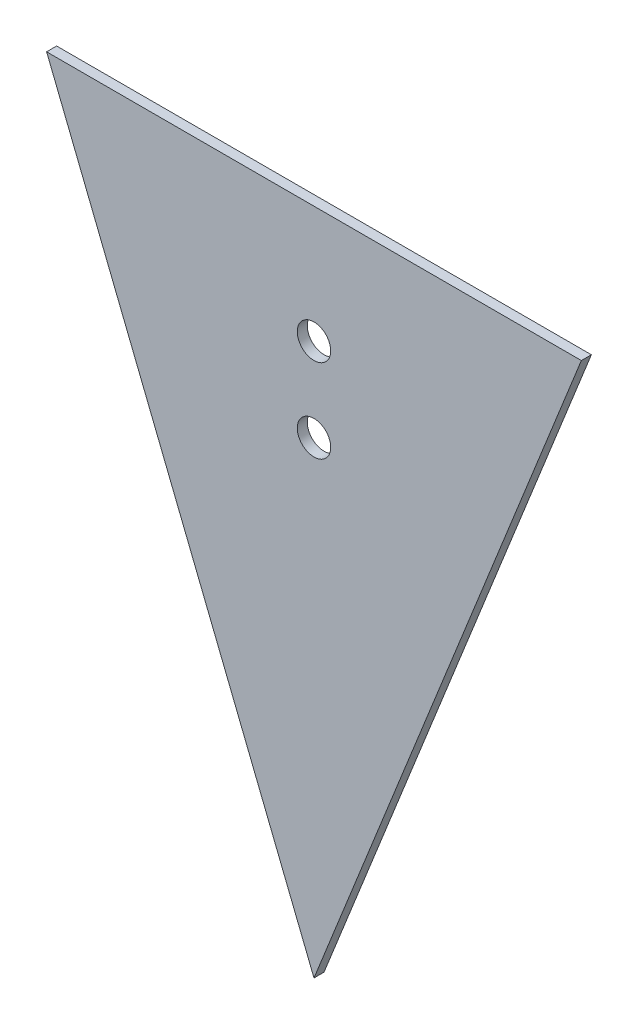
from build123d import *

# Parameters (mm, degrees)
BOSS_EXTRUDE1_DEPTH = 3
CUT_EXTRUDE1_REACH  = 5
SKETCH2_R           = 5


with BuildPart() as part:
    # Sketch1 → Boss-Extrude1 (new body)
    with BuildSketch(Plane.XY):
        Polygon((-26.901408451, -70.281690141), (53.098591549, 129.718309859), (-106.901408451, 129.718309859), align=None)
    extrude(amount=BOSS_EXTRUDE1_DEPTH)

    # Sketch2 → Cut-Extrude1 (cut, up to next)
    with BuildSketch(Plane.XY.offset(3), mode=Mode.PRIVATE) as cut_extrude1_sk1:
        with Locations((-26.901408451, 94.718309859)):
            Circle(SKETCH2_R)
    cut_extrude1_tool1 = extrude(cut_extrude1_sk1.sketch, amount=-CUT_EXTRUDE1_REACH, mode=Mode.PRIVATE) & part.part
    add(cut_extrude1_tool1.solids().sort_by_distance((-26.901408, 94.71831, 3))[0], mode=Mode.SUBTRACT)
    # Sketch2 → Cut-Extrude1 (cut, up to next)
    with BuildSketch(Plane.XY.offset(3), mode=Mode.PRIVATE) as cut_extrude1_sk2:
        with Locations((-26.901408451, 69.718309859)):
            Circle(SKETCH2_R)
    cut_extrude1_tool2 = extrude(cut_extrude1_sk2.sketch, amount=-CUT_EXTRUDE1_REACH, mode=Mode.PRIVATE) & part.part
    add(cut_extrude1_tool2.solids().sort_by_distance((-26.901408, 69.71831, 3))[0], mode=Mode.SUBTRACT)


solid = part.part
